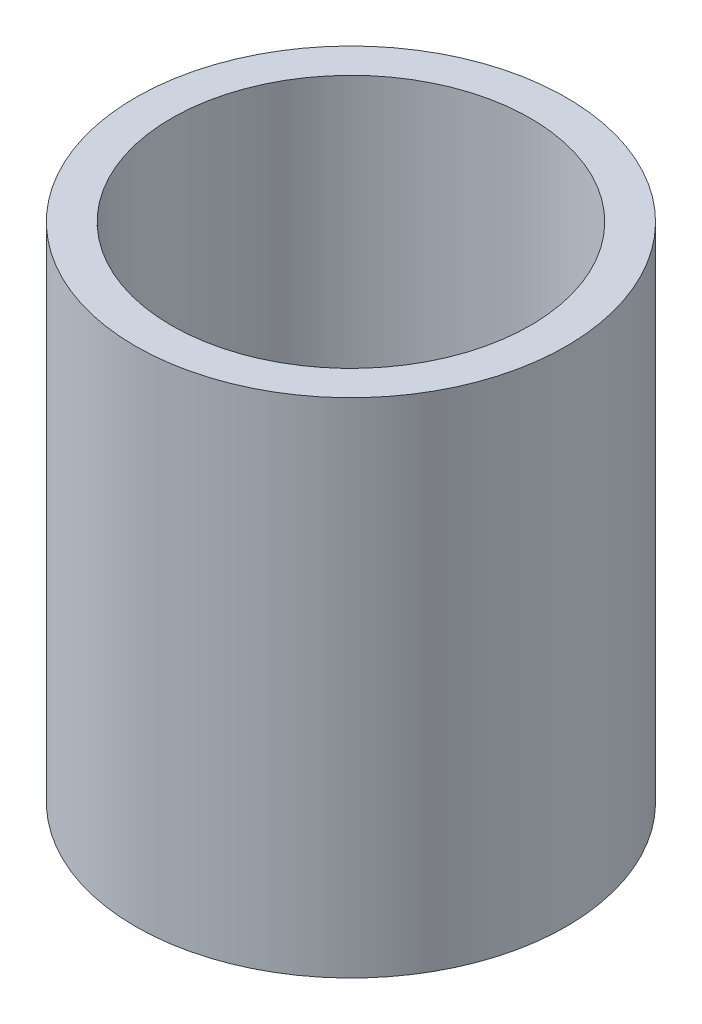
from build123d import *

# Parameters (mm, degrees)
SKETCH1_R           = 3
SKETCH1_R_2         = 2.5
BOSS_EXTRUDE1_DEPTH = 7


with BuildPart() as part:
    # Sketch1 → Boss-Extrude1 (new body)
    with BuildSketch(Plane(origin=(0, 0, 0), x_dir=(1, 0, 0), z_dir=(0, 1, 0))):
        Circle(SKETCH1_R)
        Circle(SKETCH1_R_2, mode=Mode.SUBTRACT)
    extrude(amount=BOSS_EXTRUDE1_DEPTH)


solid = part.part
